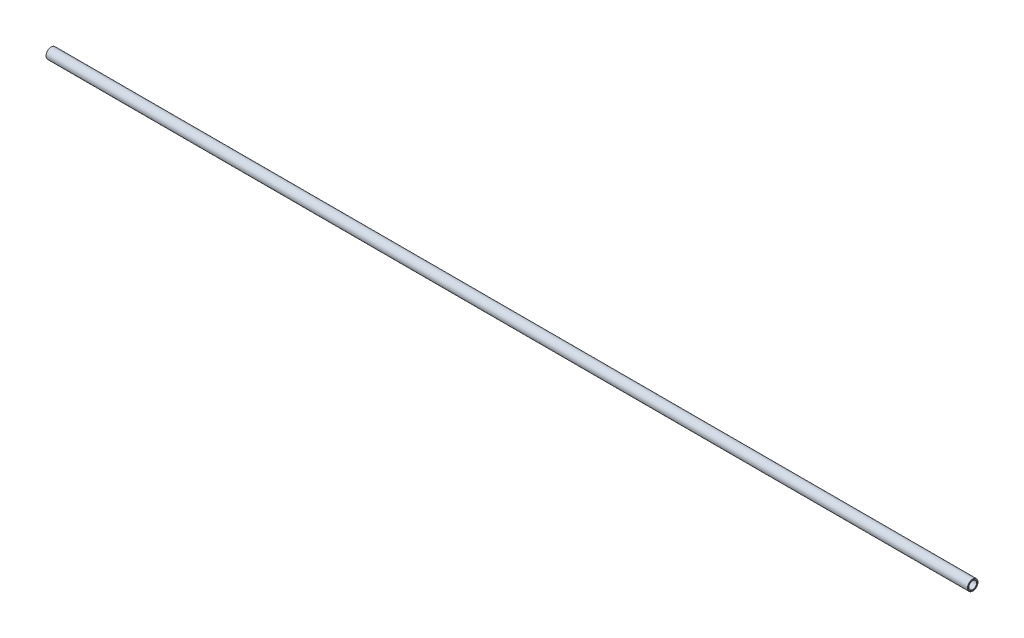
from build123d import *

# Parameters (mm, degrees)
SKETCH1_R           = 12.7
SKETCH1_R_2         = 9.525
BOSS_EXTRUDE1_DEPTH = 2235.2
CHAMFER1_SIZE       = 0.508


with BuildPart() as part:
    # Sketch1 → Boss-Extrude1 (new body)
    with BuildSketch(Plane(origin=(0, 0, 0), x_dir=(0, 0, -1), z_dir=(1, 0, 0))):
        Circle(SKETCH1_R)
        Circle(SKETCH1_R_2, mode=Mode.SUBTRACT)
    extrude(amount=BOSS_EXTRUDE1_DEPTH)

    # Chamfer1
    chamfer1_edges = [part.edges().sort_by_distance(p)[0] for p in [
        (0, 0, 12.7),
        (2235.2, 0, 12.7),
        (0, 0, 9.525),
        (2235.2, 0, 9.525),
    ]]
    chamfer(chamfer1_edges, length=CHAMFER1_SIZE)


solid = part.part
